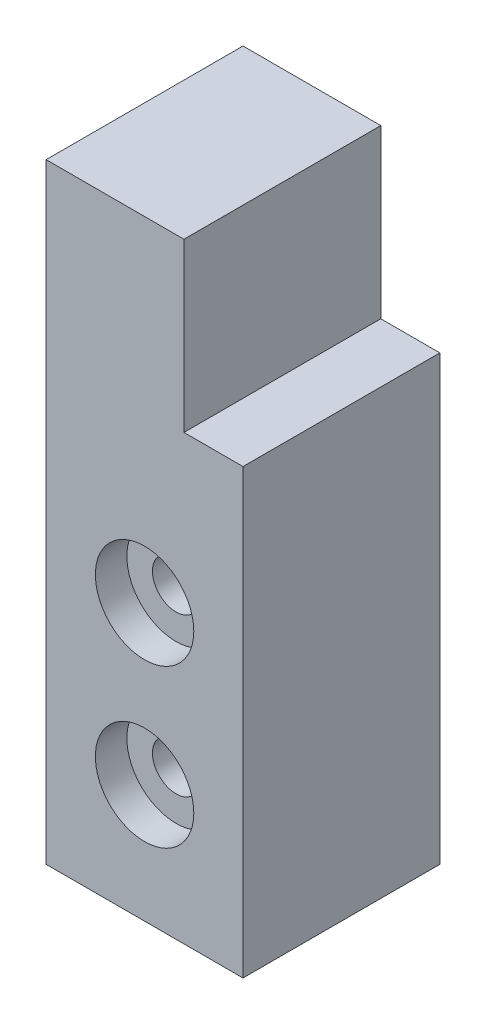
from build123d import *

# Parameters (mm, degrees)
SKETCH1_W                                = 10
SKETCH1_H                                = 31
BOSS_EXTRUDE1_DEPTH                      = 10
SKETCH2_W                                = 3
SKETCH2_H                                = 8.5
CUT_EXTRUDE1_DEPTH                       = 10
CBORE_FOR_M2_PAN_HEAD_SCREW1_D           = 2.4
CBORE_FOR_M2_PAN_HEAD_SCREW1_DEPTH       = 10
CBORE_FOR_M2_PAN_HEAD_SCREW1_CBORE_D     = 5
CBORE_FOR_M2_PAN_HEAD_SCREW1_CBORE_DEPTH = 1.6
CBORE_FOR_M2_PAN_HEAD_SCREW1_TIP         = 0.721032743


with BuildPart() as part:
    # Sketch1 → Boss-Extrude1 (new body)
    with BuildSketch(Plane.XY):
        with Locations((5, 15.5)):
            Rectangle(SKETCH1_W, SKETCH1_H)
    extrude(amount=BOSS_EXTRUDE1_DEPTH)

    # Sketch2 → Cut-Extrude1 (cut)
    with BuildSketch(Plane.XY.offset(10)):
        with Locations((8.5, 26.75)):
            Rectangle(SKETCH2_W, SKETCH2_H)
    extrude(amount=-CUT_EXTRUDE1_DEPTH, mode=Mode.SUBTRACT)

    # CBORE for M2 Pan Head Screw1
    with Locations(Plane.XY.offset(10)):
        with Locations((5, 14), (5, 6)):
            CounterBoreHole(CBORE_FOR_M2_PAN_HEAD_SCREW1_D / 2, CBORE_FOR_M2_PAN_HEAD_SCREW1_CBORE_D / 2, CBORE_FOR_M2_PAN_HEAD_SCREW1_CBORE_DEPTH, depth=CBORE_FOR_M2_PAN_HEAD_SCREW1_DEPTH)
            with Locations((0, 0, -(CBORE_FOR_M2_PAN_HEAD_SCREW1_DEPTH + CBORE_FOR_M2_PAN_HEAD_SCREW1_TIP / 2))):  # 118° drill point
                Cone(0, CBORE_FOR_M2_PAN_HEAD_SCREW1_D / 2, CBORE_FOR_M2_PAN_HEAD_SCREW1_TIP, mode=Mode.SUBTRACT)


solid = part.part
